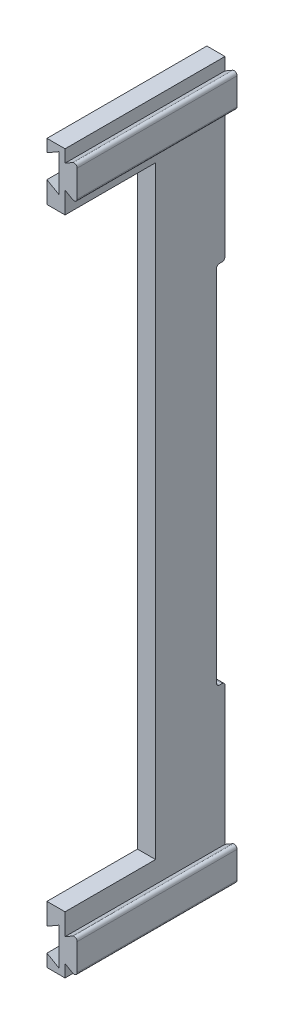
from build123d import *

# Parameters (mm, degrees)
BOSS_EXTRUDE1_DEPTH = 53
CUT_EXTRUDE1_DEPTH  = 52
FILLET1_R           = 1
FILLET3_R           = 1
SKETCH4_W           = 30
SKETCH4_H           = 200
CUT_EXTRUDE2_DEPTH  = 10


with BuildPart() as part:
    # Sketch2 → Boss-Extrude1 (new body)
    with BuildSketch(Plane.XY):
        Polygon((0, 0), (0, -4.14), (4.00969762, -1.825), (4.00969762, -14.175), (0, -11.86), (0, -19), (0, -219), (0, -226.14), (4.00969762, -223.825), (4.00969762, -236.175), (0, -233.86), (0, -238), (6, -238), (6, -233.86), (10.00969762, -236.175), (10.00969762, -223.825), (6, -226.14), (6, -11.86), (10.00969762, -14.175), (10.00969762, -1.825), (6, -4.14), (6, 0), align=None)
    extrude(amount=BOSS_EXTRUDE1_DEPTH)

    # Sketch3 → Cut-Extrude1 (cut)
    with BuildSketch(Plane(origin=(0, 0, 0), x_dir=(0, 0, -1), z_dir=(1, 0, 0))):
        Polygon((0, -119), (0, -58.5), (-2.8, -58.5), (-2.8, -179.5), (0, -179.5), align=None)
    extrude(amount=CUT_EXTRUDE1_DEPTH, mode=Mode.SUBTRACT)

    # Fillet1
    fillet1_edges = [part.edges().sort_by_distance(p)[0] for p in [
        (3, -179.5, 0),
        (3, -58.5, 0),
        (3, -58.5, 2.8),
        (0, -119, 2.8),
        (0, -58.5, 1.4),
        (3, -179.5, 2.8),
        (0, -179.5, 1.4),
    ]]
    fillet(fillet1_edges, radius=FILLET1_R)

    # Fillet3
    fillet3_edges = [part.edges().sort_by_distance(p)[0] for p in [
        (10.00969762, -1.825, 26.5),
        (10.00969762, -14.175, 26.5),
        (10.00969762, -223.825, 26.5),
        (10.00969762, -236.175, 26.5),
    ]]
    fillet(fillet3_edges, radius=FILLET3_R)

    # Sketch4 → Cut-Extrude2 (cut)
    with BuildSketch(Plane(origin=(6, 0, 0), x_dir=(0, 0, -1), z_dir=(1, 0, 0))):
        with Locations((-38, -119)):
            Rectangle(SKETCH4_W, SKETCH4_H)
    extrude(amount=-CUT_EXTRUDE2_DEPTH, mode=Mode.SUBTRACT)


solid = part.part
